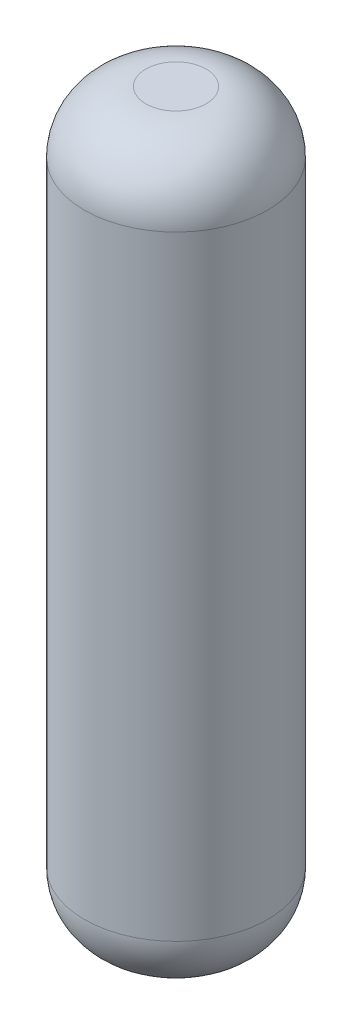
from build123d import *

# Parameters (mm, degrees)
SKETCH1_R           = 75.727177351
BOSS_EXTRUDE1_DEPTH = 609.6
FILLET1_R           = 50.8


with BuildPart() as part:
    # Sketch1 → Boss-Extrude1 (new body)
    with BuildSketch(Plane(origin=(0, 0, 0), x_dir=(1, 0, 0), z_dir=(0, 1, 0))):
        Circle(SKETCH1_R)
    extrude(amount=BOSS_EXTRUDE1_DEPTH)

    # Fillet1
    fillet1_edges = [part.edges().sort_by_distance(p)[0] for p in [
        (-75.727177351, 0, 0),
        (-75.727177351, 609.6, 0),
    ]]
    fillet(fillet1_edges, radius=FILLET1_R)


solid = part.part
